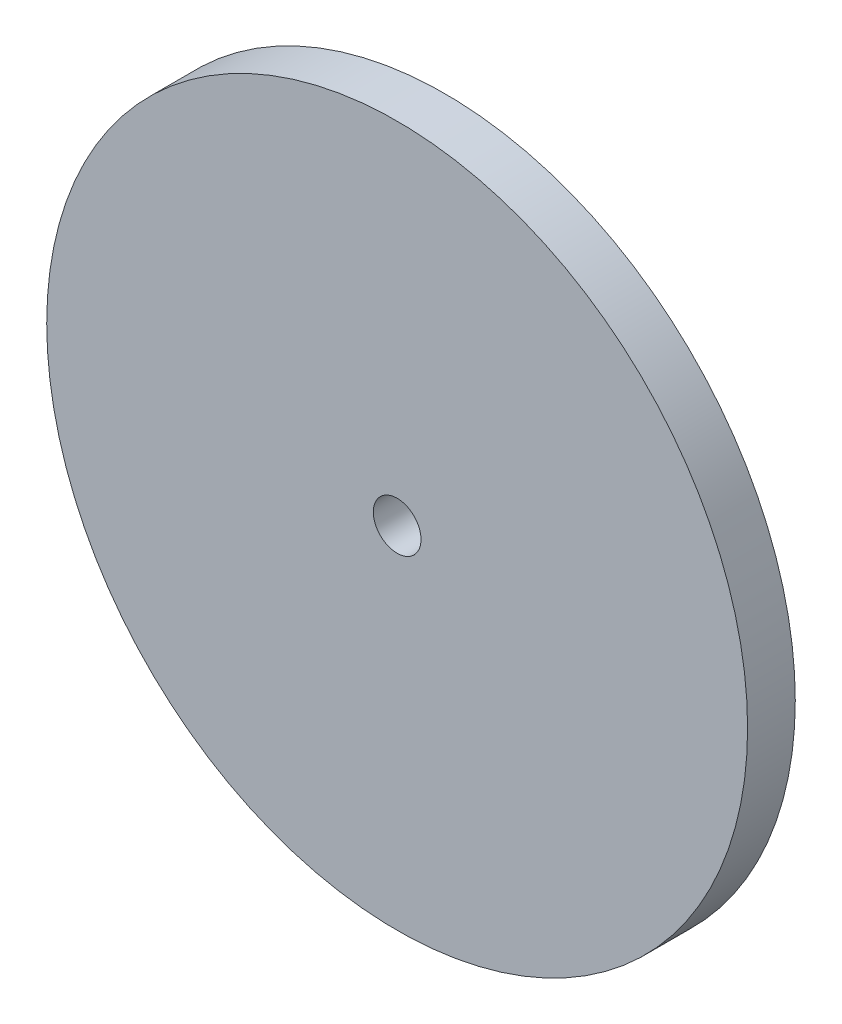
from build123d import *

# Parameters (mm, degrees)
SKETCH1_R           = 7.35
SKETCH1_R_2         = 0.5
BOSS_EXTRUDE1_DEPTH = 1


with BuildPart() as part:
    # Sketch1 → Boss-Extrude1 (new body)
    with BuildSketch(Plane.XY):
        Circle(SKETCH1_R)
        Circle(SKETCH1_R_2, mode=Mode.SUBTRACT)
    extrude(amount=BOSS_EXTRUDE1_DEPTH)


solid = part.part
